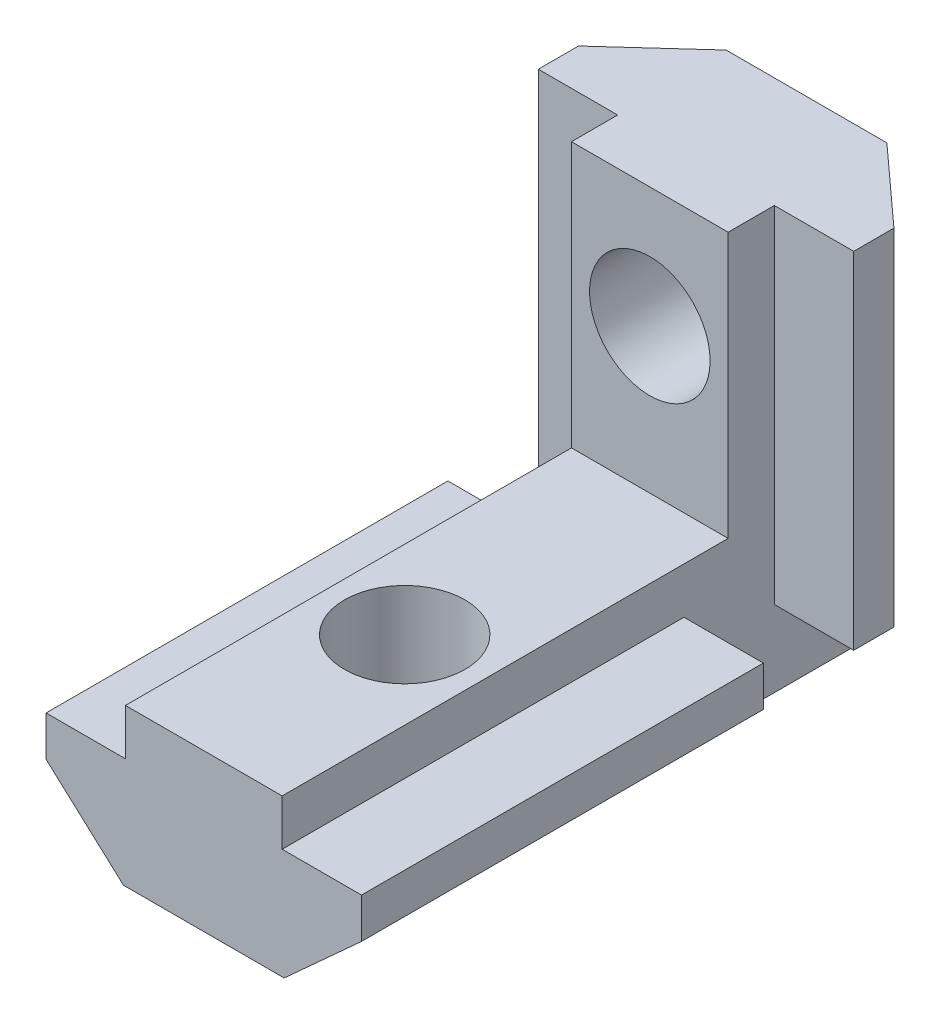
from build123d import *

# Parameters (mm, degrees)
EXTRUDE_1_DEPTH      = 20
EXTRUDE_1_DEPTH_BACK = 0.0001
SKETCH_2_W           = 7.8
SKETCH_2_H           = 7.8
EXTRUDE_2_DEPTH      = 10
EXTRUDE_3_DEPTH      = 13.2
EXTRUDE_3_DEPTH_BACK = 4
SKETCH_4_R           = 3
CUT_EXTRUDE_1_DEPTH  = 11.615262649
SKETCH_5_R           = 3
CUT_EXTRUDE_2_DEPTH  = 8.8
SKETCH_6_W           = 7.8
SKETCH_6_H           = 2.815262649
CUT_EXTRUDE_3_DEPTH  = 21.0001


with BuildPart() as part:
    # Эскиз1 → Бобышка-Вытянуть1 (new body, two sides)
    with BuildSketch(Plane.XY) as extrude_1_sk:
        Polygon((-3.9, 8.315262649), (3.9, 8.315262649), (3.9, 3.2), (7.85, 3.2), (7.85, 1.2), (4, -2.3), (-4, -2.3), (-7.85, 1.2), (-7.85, 3.2), (-3.9, 3.2), align=None)
    extrude(amount=EXTRUDE_1_DEPTH)
    extrude(extrude_1_sk.sketch, amount=-EXTRUDE_1_DEPTH_BACK)

    # Эскиз2 → Бобышка-Вытянуть2 (add)
    with BuildSketch(Plane(origin=(0, 0, -0.0001), x_dir=(-1, 0, 0), z_dir=(0, 0, -1))):
        with Locations((0, 1.6)):
            Rectangle(SKETCH_2_W, SKETCH_2_H)
    extrude(amount=EXTRUDE_2_DEPTH)

    # Эскиз3 → Бобышка-Вытянуть3 (add, two sides)
    with BuildSketch(Plane(origin=(0, 5.5, 0), x_dir=(1, 0, 0), z_dir=(0, 1, 0))) as extrude_3_sk:
        Polygon((3.9, 2.2001), (-3.9, 2.2001), (-3.9, 4.5001), (-7.85, 4.5001), (-7.85, 6.5001), (-4, 10.0001), (4, 10.0001), (7.85, 6.5001), (7.85, 4.5001), (3.9, 4.5001), align=None)
    extrude(amount=EXTRUDE_3_DEPTH)
    extrude(extrude_3_sk.sketch, amount=-EXTRUDE_3_DEPTH_BACK)

    # Эскиз4 → Вырез-Вытянуть1 (cut, through all)
    with BuildSketch(Plane(origin=(0, 8.315262649, 0), x_dir=(1, 0, 0), z_dir=(0, 1, 0))):
        with Locations(Location((0, -10, 0), (0, 0, 180))):  # turned: the seam where the file's is
            Circle(SKETCH_4_R)
    extrude(amount=-CUT_EXTRUDE_1_DEPTH, mode=Mode.SUBTRACT)

    # Эскиз5 → Вырез-Вытянуть2 (cut, through all)
    with BuildSketch(Plane.XY.offset(-2.2001)):
        with Locations((0, 12.7)):
            Circle(SKETCH_5_R)
    extrude(amount=-CUT_EXTRUDE_2_DEPTH, mode=Mode.SUBTRACT)

    # Эскиз6 → Вырез-Вытянуть3 (cut, through all)
    with BuildSketch(Plane(origin=(0, 0, -0.0001), x_dir=(-1, 0, 0), z_dir=(0, 0, -1))):
        with Locations((0, 6.907631325)):
            Rectangle(SKETCH_6_W, SKETCH_6_H)
    extrude(amount=-CUT_EXTRUDE_3_DEPTH, mode=Mode.SUBTRACT)


solid = part.part
